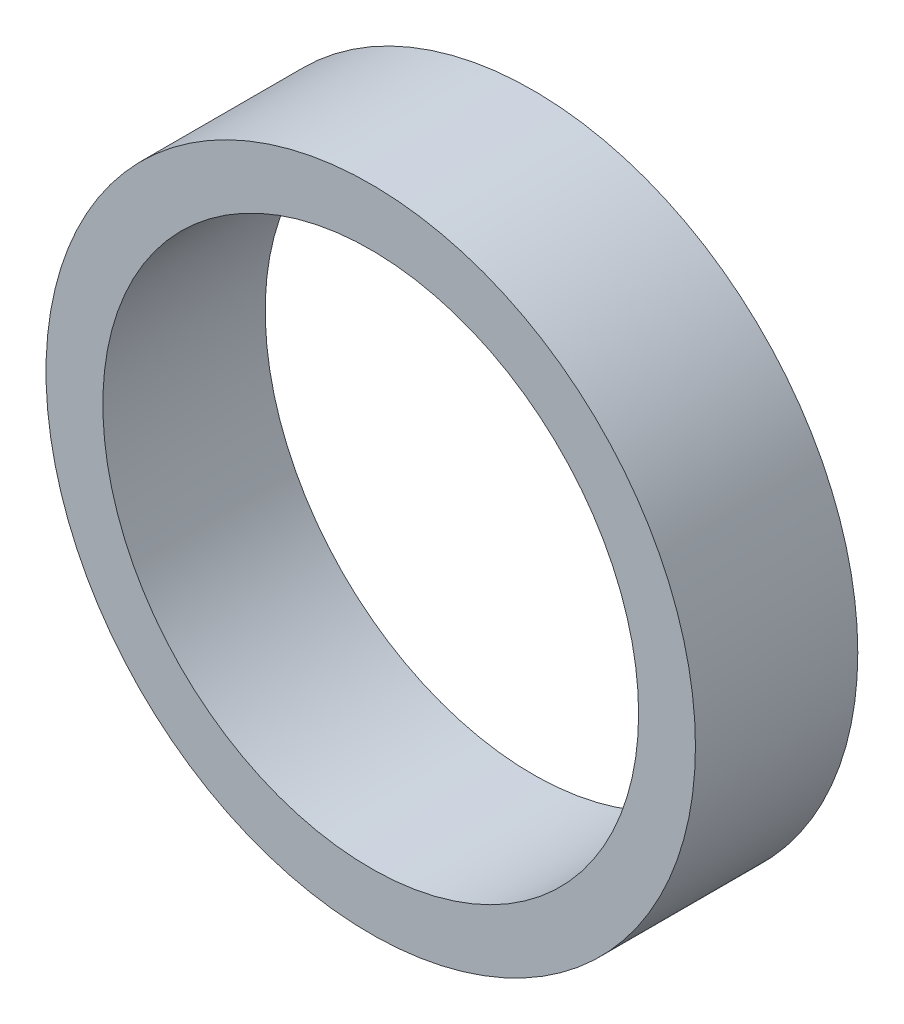
from build123d import *

# Parameters (mm, degrees)
SKETCH_1_R      = 40
SKETCH_1_R_2    = 33
EXTRUDE_1_DEPTH = 20


with BuildPart() as part:
    # 草图1 → 凸台-拉伸1 (new body)
    with BuildSketch(Plane.XY):
        Circle(SKETCH_1_R)
        Circle(SKETCH_1_R_2, mode=Mode.SUBTRACT)
    extrude(amount=-EXTRUDE_1_DEPTH)


solid = part.part
